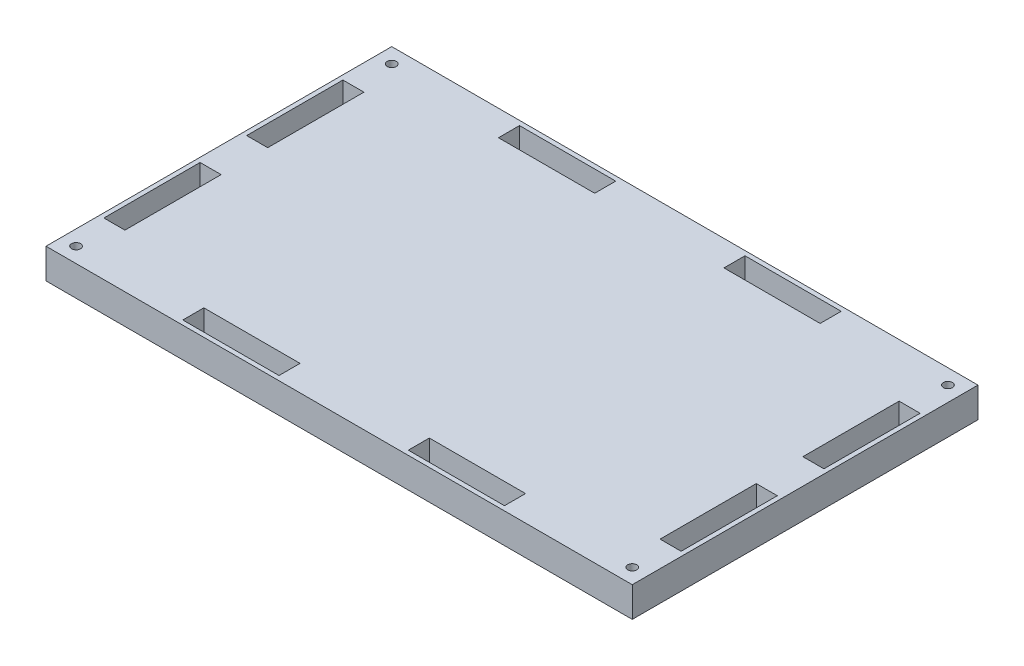
from build123d import *

# Parameters (mm, degrees)
ESBO_O1_W                = 195
ESBO_O1_H                = 115
RESSALTO_EXTRUS_O1_DEPTH = 10
ESBO_O2_W                = 32
ESBO_O2_H                = 7
ESBO_O2_W_2              = 7
ESBO_O2_H_2              = 32
CORTE_EXTRUS_O2_DEPTH    = 11
ESBO_O3_R                = 1.5
CORTE_EXTRUS_O3_DEPTH    = 11


with BuildPart() as part:
    # Esboço1 → Ressalto-extrusão1 (new body)
    with BuildSketch(Plane(origin=(0, 0, 0), x_dir=(1, 0, 0), z_dir=(0, 1, 0))):
        Rectangle(ESBO_O1_W, ESBO_O1_H)
    extrude(amount=RESSALTO_EXTRUS_O1_DEPTH)

    # Esboço2 → Corte-extrusão2 (cut, through all)
    with BuildSketch(Plane(origin=(0, 10, 0), x_dir=(1, 0, 0), z_dir=(0, 1, 0))):
        with Locations((-37.5, -52.5)):
            Rectangle(ESBO_O2_W, ESBO_O2_H)
        with Locations((37.5, -52.5)):
            Rectangle(ESBO_O2_W, ESBO_O2_H)
        with Locations((37.5, 52.5)):
            Rectangle(ESBO_O2_W, ESBO_O2_H)
        with Locations((-37.5, 52.5)):
            Rectangle(ESBO_O2_W, ESBO_O2_H)
        with Locations((-92.5, 23.75)):
            Rectangle(ESBO_O2_W_2, ESBO_O2_H_2)
        with Locations((-92.5, -23.75)):
            Rectangle(ESBO_O2_W_2, ESBO_O2_H_2)
        with Locations((92.5, -23.75)):
            Rectangle(ESBO_O2_W_2, ESBO_O2_H_2)
        with Locations((92.5, 23.75)):
            Rectangle(ESBO_O2_W_2, ESBO_O2_H_2)
    extrude(amount=-CORTE_EXTRUS_O2_DEPTH, mode=Mode.SUBTRACT)

    # Esboço3 → Corte-extrusão3 (cut, through all)
    with BuildSketch(Plane(origin=(0, 10, 0), x_dir=(1, 0, 0), z_dir=(0, 1, 0))):
        with Locations((-92.5, 52.5)):
            Circle(ESBO_O3_R)
        with Locations((92.5, 52.5)):
            Circle(ESBO_O3_R)
        with Locations((92.5, -52.5)):
            Circle(ESBO_O3_R)
        with Locations((-92.5, -52.5)):
            Circle(ESBO_O3_R)
    extrude(amount=-CORTE_EXTRUS_O3_DEPTH, mode=Mode.SUBTRACT)


solid = part.part
